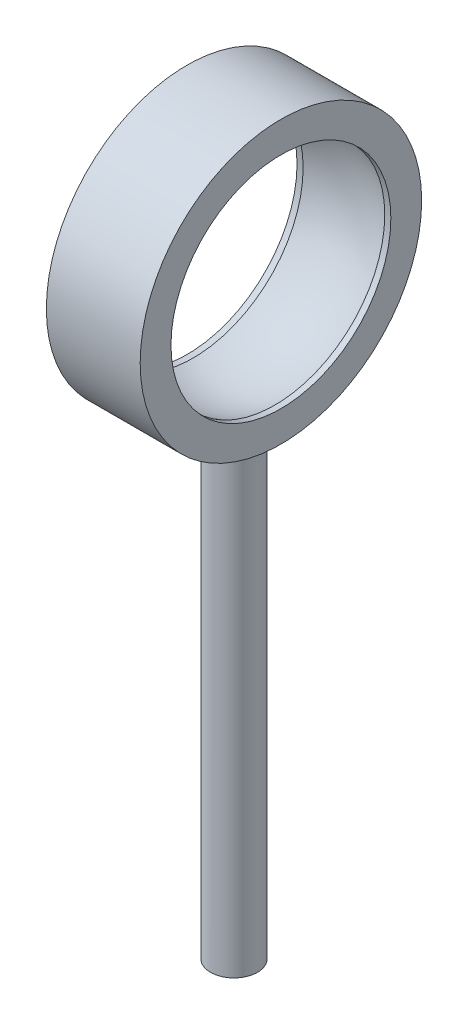
from build123d import *


with BuildPart() as part:
    # Sketch1 → Revolve1 (revolve)
    with BuildSketch(Plane.XY):
        with BuildLine():
            Line((2.54, 7.62), (-2.54, 7.62))
            Line((-2.54, 7.62), (-2.54, 5.953125))
            Line((-2.54, 5.953125), (-2.209706481, 5.953125))
            ThreePointArc((-2.209706481, 5.953125), (0, 6.35), (2.209706481, 5.953125))
            Line((2.209706481, 5.953125), (2.54, 5.953125))
            Line((2.54, 5.953125), (2.54, 7.62))
        make_face()
    revolve(axis=Axis((-10.16, 0, 0), (1, 0, 0)))

    # Sketch2 → Revolve2 (revolve)
    with BuildSketch(Plane(origin=(0, 0, 0), x_dir=(0, 0, -1), z_dir=(1, 0, 0))):
        with BuildLine():
            Line((1.27, -7.513421325), (1.27, -33.02))
            Line((1.27, -33.02), (0, -33.02))
            Line((0, -33.02), (0, -7.62))
            ThreePointArc((0, -7.62), (0.637232103, -7.593308584), (1.27, -7.513421325))
        make_face()
    revolve(axis=Axis((0, -33.02, 0), (0, 1, 0)))


solid = part.part
